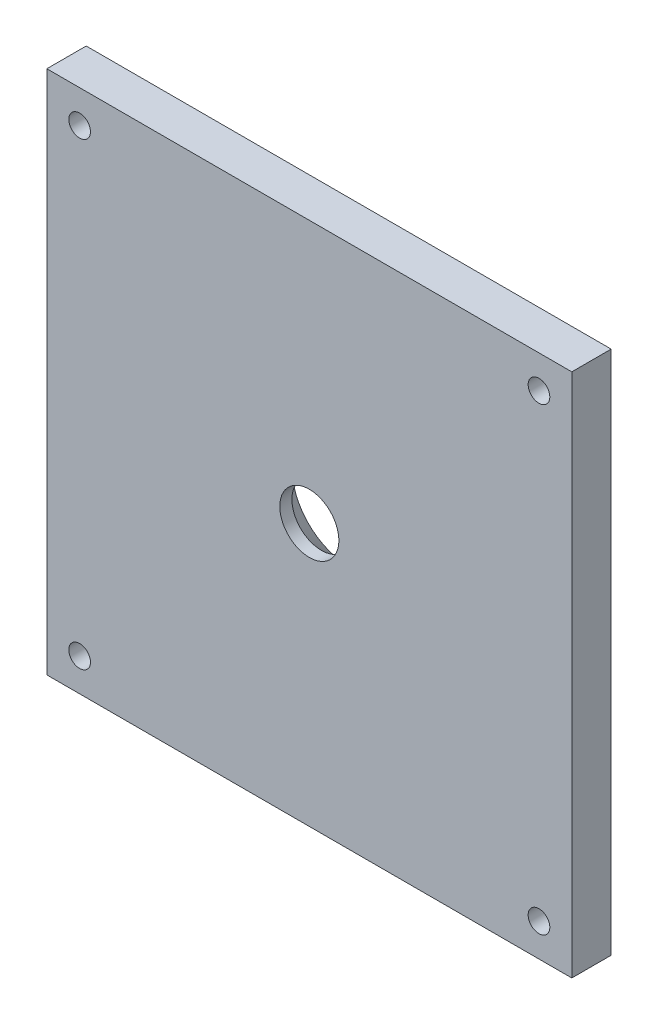
from build123d import *

# Parameters (mm, degrees)
SKIZZE1_W                       = 80
SKIZZE1_H                       = 80
SKIZZE1_R                       = 2.5
AUFSATZ_LINEAR_AUSTRAGEN1_DEPTH = 6
M4_GEWINDEBOHRUNG2_D            = 3.3
M4_GEWINDEBOHRUNG2_DEPTH        = 11.5
M4_GEWINDEBOHRUNG2_TIP          = 0.991420021


with BuildPart() as part:
    # Skizze1 → Aufsatz-Linear austragen1 (new body)
    with BuildSketch(Plane.XY):
        Rectangle(SKIZZE1_W, SKIZZE1_H)
        Circle(SKIZZE1_R, mode=Mode.SUBTRACT)
    extrude(amount=AUFSATZ_LINEAR_AUSTRAGEN1_DEPTH)

    # M4 Gewindebohrung2
    with Locations(Plane(origin=(0, 0, 0), x_dir=(-1, 0, 0), z_dir=(0, 0, -1))):
        with Locations((35, 35), (35, -35), (-35, -35), (-35, 35)):
            Hole(M4_GEWINDEBOHRUNG2_D / 2, depth=M4_GEWINDEBOHRUNG2_DEPTH)
            with Locations((0, 0, -(M4_GEWINDEBOHRUNG2_DEPTH + M4_GEWINDEBOHRUNG2_TIP / 2))):  # 118° drill point
                Cone(0, M4_GEWINDEBOHRUNG2_D / 2, M4_GEWINDEBOHRUNG2_TIP, mode=Mode.SUBTRACT)

    # Skizze8 → Formsenkung für M8 Linsensenkschraube1 (revolve, cut)
    with BuildSketch(Plane.YZ):
        Polygon((0, 0), (0, 6), (4.5, 6), (4.5, 4.15), (8.65, 0), align=None)
    revolve(axis=Axis((0, 0, -6.35), (0, 0, 1)), mode=Mode.SUBTRACT)


solid = part.part
